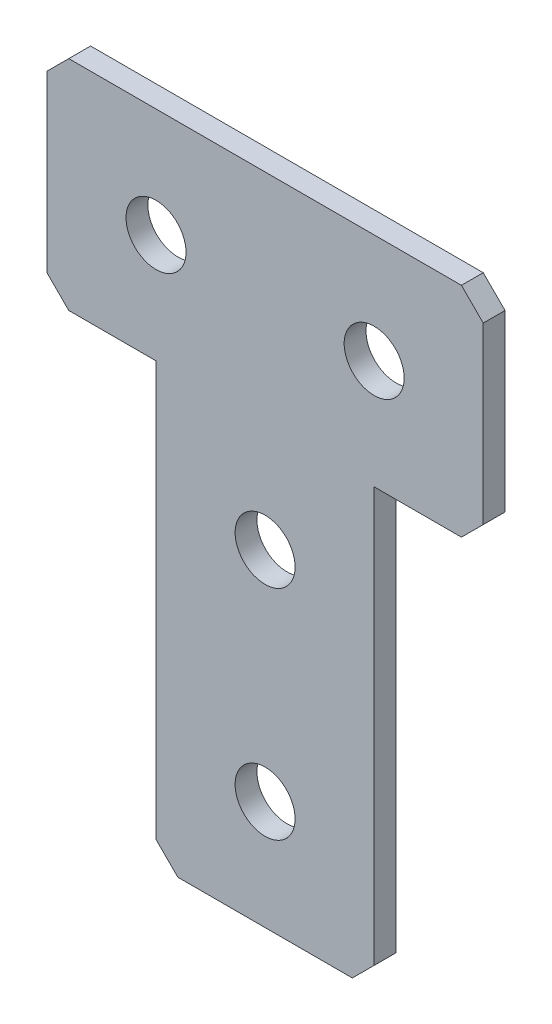
from build123d import *

# Parameters (mm, degrees)
EXTRUDE_1_DEPTH   = 2
CHAMFER_1_SIZE    = 2
HOLE_WIZARD_M51_D = 5.5


with BuildPart() as part:
    # Эскиз1 → Бобышка-Вытянуть1 (new body)
    with BuildSketch(Plane(origin=(0, 0, 0), x_dir=(1, 0, 0), z_dir=(0, 0, -1))):
        Polygon((10, 0), (-10, 0), (-10, -40), (-20, -40), (-20, -60), (20, -60), (20, -40), (10, -40), align=None)
    extrude(amount=EXTRUDE_1_DEPTH)

    # Фаска1
    chamfer_1_edges = [part.edges().sort_by_distance(p)[0] for p in [
        (-10, 0, -1),
        (10, 0, -1),
        (20, 40, -1),
        (20, 60, -1),
        (-20, 60, -1),
        (-20, 40, -1),
    ]]
    chamfer(chamfer_1_edges, length=CHAMFER_1_SIZE)

    # Отверстие с зазором M51 (through all)
    with Locations(Plane.XY):
        with Locations((-10, 50), (10, 50), (0, 30), (0, 10)):
            Hole(HOLE_WIZARD_M51_D / 2)


solid = part.part
